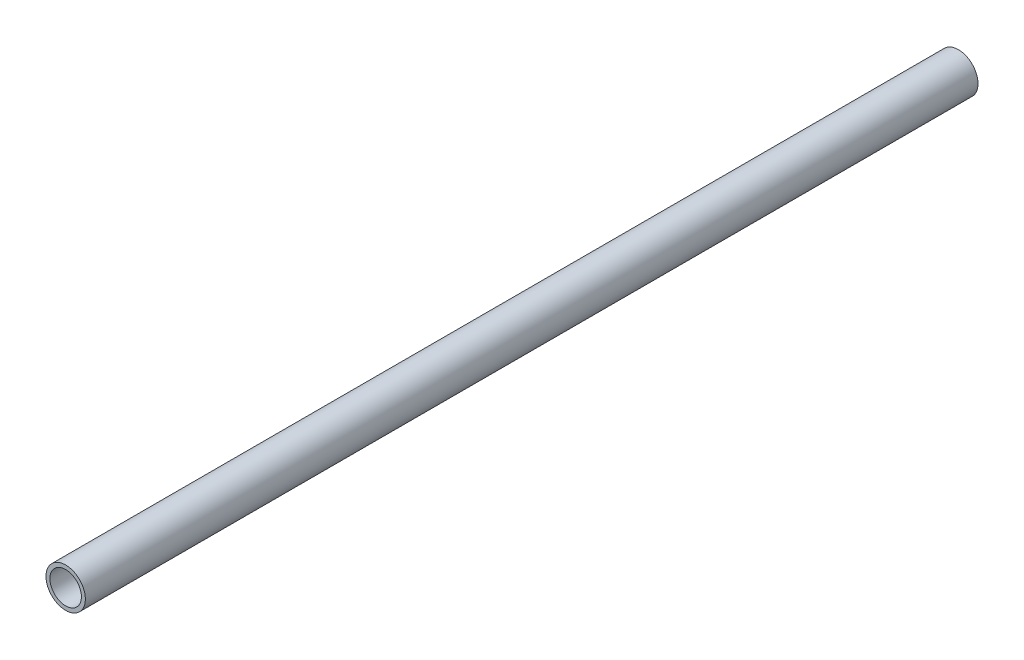
from build123d import *

# Parameters (mm, degrees)
ESQUISSE1_R             = 7.5
ESQUISSE1_R_2           = 6
BOSS_EXTRU_1_DEPTH      = 300
BOSS_EXTRU_1_DEPTH_BACK = 40


with BuildPart() as part:
    # Esquisse1 → Boss.-Extru.1 (new body, two sides)
    with BuildSketch(Plane.XY) as boss_extru_1_sk:
        with Locations((30, 0)):
            Circle(ESQUISSE1_R)
        with Locations((30, 0)):
            Circle(ESQUISSE1_R_2, mode=Mode.SUBTRACT)
    extrude(amount=BOSS_EXTRU_1_DEPTH)
    extrude(boss_extru_1_sk.sketch, amount=-BOSS_EXTRU_1_DEPTH_BACK)


solid = part.part
